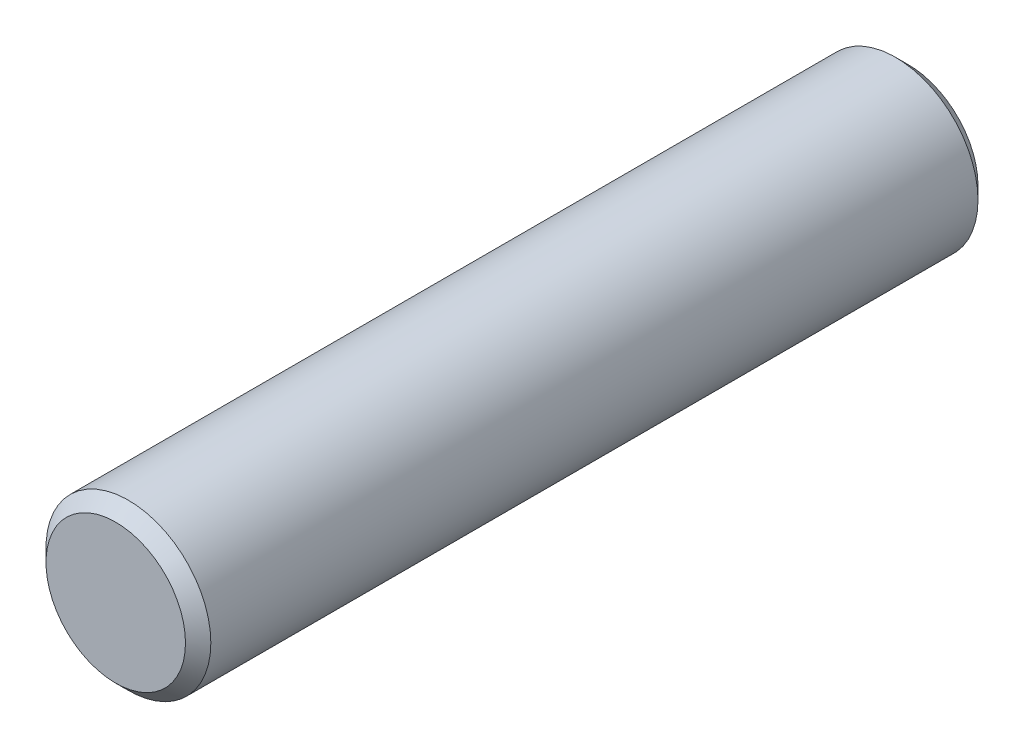
from build123d import *

# Parameters (mm, degrees)
SKETCH1_R           = 1.651
BOSS_EXTRUDE1_DEPTH = 7.9375
CHAMFER1_SIZE       = 0.254


with BuildPart() as part:
    # Sketch1 → Boss-Extrude1 (new body, symmetric)
    with BuildSketch(Plane.XY):
        Circle(SKETCH1_R)
    extrude(amount=BOSS_EXTRUDE1_DEPTH, both=True)

    # Chamfer1
    chamfer1_edges = [part.edges().sort_by_distance(p)[0] for p in [
        (-1.651, 0, -7.9375),
        (-1.651, 0, 7.9375),
    ]]
    chamfer(chamfer1_edges, length=CHAMFER1_SIZE)


solid = part.part
